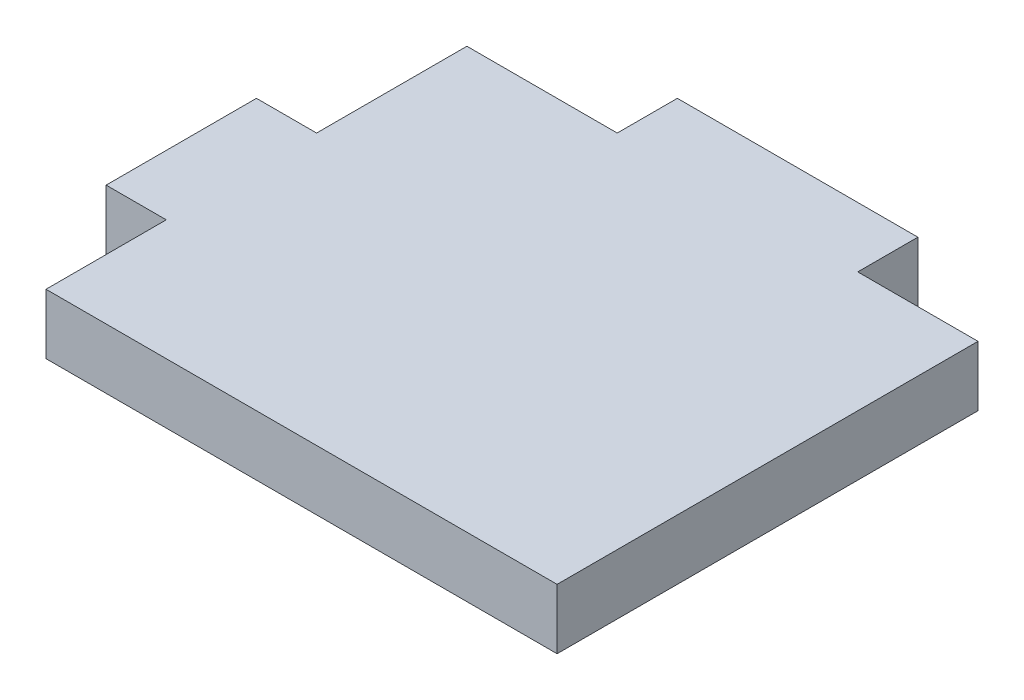
from build123d import *

# Parameters (mm, degrees)
BOSS_EXTRUDE1_DEPTH = 10


with BuildPart() as part:
    # Sketch1 → Boss-Extrude1 (new body)
    with BuildSketch(Plane(origin=(0, 0, 0), x_dir=(1, 0, 0), z_dir=(0, 1, 0))):
        Polygon((95, 0), (10, 0), (10, 20), (0, 20), (0, 45), (10, 45), (10, 70), (35, 70), (35, 80), (75, 80), (75, 70), (95, 70), align=None)
    extrude(amount=BOSS_EXTRUDE1_DEPTH)


solid = part.part
